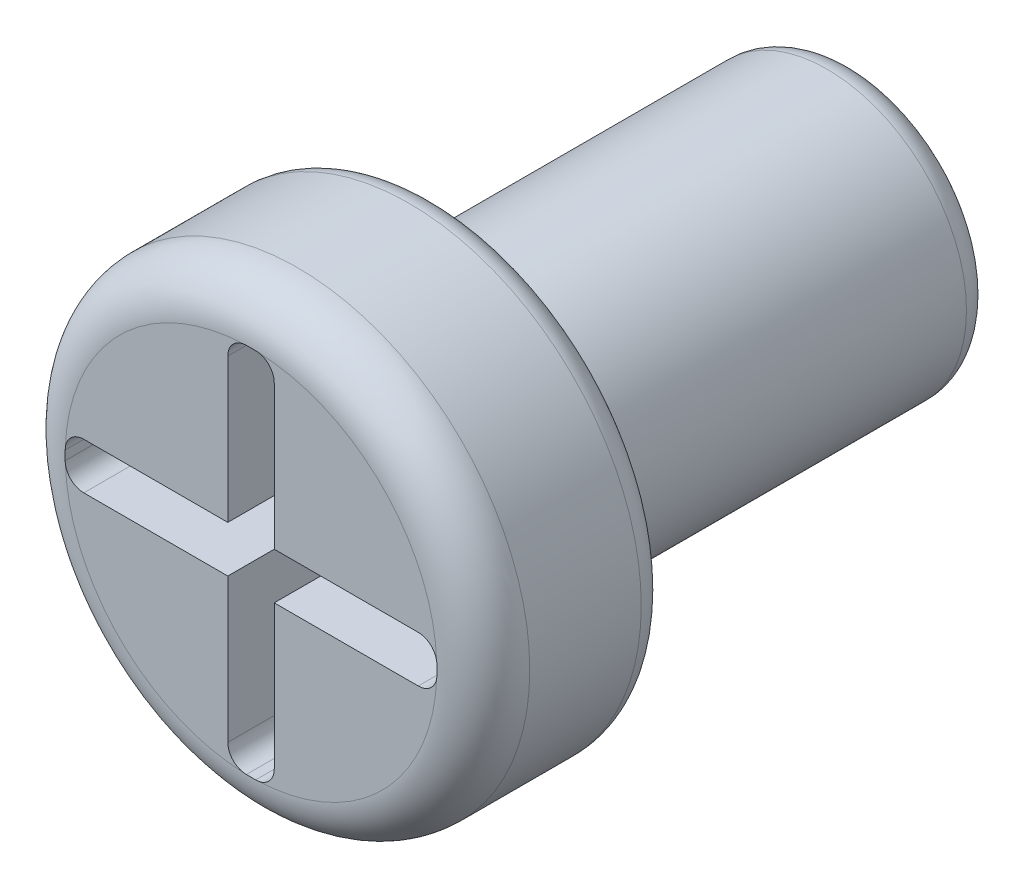
from build123d import *

# Parameters (mm, degrees)
IZIM1_R                     = 1.5
Y_KSEKLIK_EKSTR_ZYON1_DEPTH = 4.5
IZIM2_R                     = 2.5
Y_KSEKLIK_EKSTR_ZYON2_DEPTH = 2
RADYUS1_R                   = 0.5
RADYUS2_R                   = 0.3
KES_EKSTR_ZYON1_DEPTH       = 1.5


with BuildPart() as part:
    # Çizim1 → Yükseklik-Ekstrüzyon1 (new body)
    with BuildSketch(Plane.XY):
        Circle(IZIM1_R)
    extrude(amount=-Y_KSEKLIK_EKSTR_ZYON1_DEPTH)

    # Çizim2 → Yükseklik-Ekstrüzyon2 (add)
    with BuildSketch(Plane.XY):
        Circle(IZIM2_R)
    extrude(amount=Y_KSEKLIK_EKSTR_ZYON2_DEPTH)

    # Radyus1
    radyus1_edges = [part.edges().sort_by_distance(p)[0] for p in [
        (-2.5, 0, 2),
    ]]
    fillet(radyus1_edges, radius=RADYUS1_R)

    # Radyus2
    radyus2_edges = [part.edges().sort_by_distance(p)[0] for p in [
        (-1.5, 0, -4.5),
        (-2.5, 0, 0),
    ]]
    fillet(radyus2_edges, radius=RADYUS2_R)

    # Çizim3 → Kes-Ekstrüzyon1 (cut)
    with BuildSketch(Plane.XY.offset(2)):
        with BuildLine():
            Line((-0.05, 2), (0.05, 2))
            ThreePointArc((0.05, 2), (0.191421356, 1.941421356), (0.25, 1.8))
            Line((0.25, 1.8), (0.25, 0.25))
            Line((0.25, 0.25), (1.8, 0.25))
            ThreePointArc((1.8, 0.25), (1.941421356, 0.191421356), (2, 0.05))
            Line((2, 0.05), (2, -0.05))
            ThreePointArc((2, -0.05), (1.941421356, -0.191421356), (1.8, -0.25))
            Line((1.8, -0.25), (0.25, -0.25))
            Line((0.25, -0.25), (0.25, -1.8))
            ThreePointArc((0.25, -1.8), (0.191421356, -1.941421356), (0.05, -2))
            Line((0.05, -2), (-0.05, -2))
            ThreePointArc((-0.05, -2), (-0.191421356, -1.941421356), (-0.25, -1.8))
            Line((-0.25, -1.8), (-0.25, -0.25))
            Line((-0.25, -0.25), (-1.8, -0.25))
            ThreePointArc((-1.8, -0.25), (-1.941421356, -0.191421356), (-2, -0.05))
            Line((-2, -0.05), (-2, 0.05))
            ThreePointArc((-2, 0.05), (-1.941421356, 0.191421356), (-1.8, 0.25))
            Line((-1.8, 0.25), (-0.25, 0.25))
            Line((-0.25, 0.25), (-0.25, 1.8))
            ThreePointArc((-0.25, 1.8), (-0.191421356, 1.941421356), (-0.05, 2))
        make_face()
    extrude(amount=-KES_EKSTR_ZYON1_DEPTH, mode=Mode.SUBTRACT)


solid = part.part
